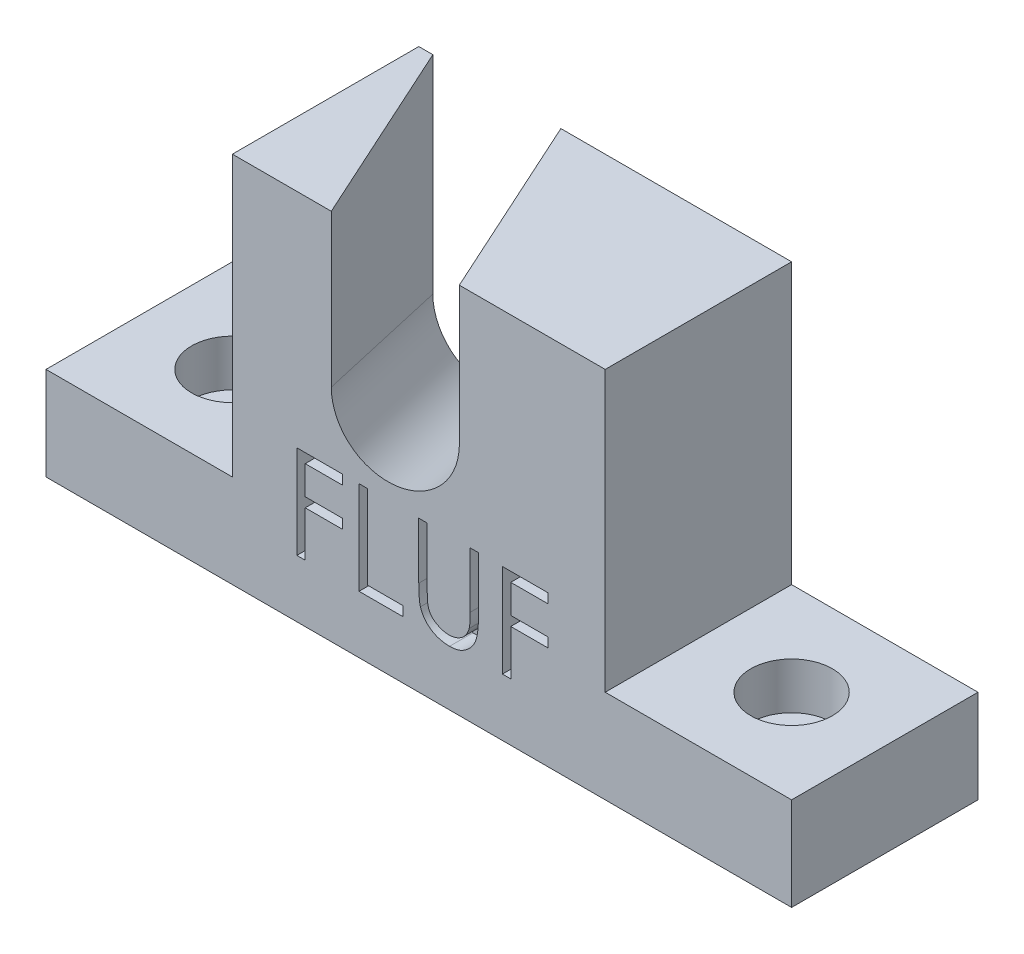
from build123d import *

# Parameters (mm, degrees)
BOSS_EXTRUDE1_DEPTH                              = 25.4
CBORE_FOR_1_4_SOCKET_HEAD_CAP_SCREW1_D           = 6.7564
CBORE_FOR_1_4_SOCKET_HEAD_CAP_SCREW1_CBORE_D     = 11.1125
CBORE_FOR_1_4_SOCKET_HEAD_CAP_SCREW1_CBORE_DEPTH = 6.35
SKETCH6_R                                        = 7.9375
CUT_EXTRUDE2_DEPTH                               = 88.530033839
CUT_EXTRUDE3_DEPTH                               = 3.175


with BuildPart() as part:
    # Sketch1 → Boss-Extrude1 (new body)
    with BuildSketch(Plane.XY):
        Polygon((25.4, 12.7), (50.8, 12.7), (50.8, 0), (-50.8, 0), (-50.8, 12.7), (-25.4, 12.7), (-25.4, 50.8), (25.4, 50.8), align=None)
    extrude(amount=BOSS_EXTRUDE1_DEPTH)

    # CBORE for 1/4 Socket Head Cap Screw1 (through all)
    with Locations(Plane(origin=(0, 12.7, 0), x_dir=(1, 0, 0), z_dir=(0, 1, 0))):
        with Locations((-38.1, -12.7), (38.1, -12.7)):
            CounterBoreHole(CBORE_FOR_1_4_SOCKET_HEAD_CAP_SCREW1_D / 2, CBORE_FOR_1_4_SOCKET_HEAD_CAP_SCREW1_CBORE_D / 2, CBORE_FOR_1_4_SOCKET_HEAD_CAP_SCREW1_CBORE_DEPTH)

    # Sketch6 → Cut-Extrude2 (cut, through all)
    with BuildSketch(Plane(origin=(8.61013147, 38.672281651, 51.345863849), x_dir=(-0.9161407044196058, 0.08766347581543056, 0.39115383765662576), z_dir=(-0.40011338654688333, -0.2593820230581922, -0.878993881673942))):
        Circle(SKETCH6_R)
        with BuildLine():
            Line((-4.081369276, 42.668005296), (-7.904732998, 0.720487673))
            ThreePointArc((-7.904732998, 0.720487673), (0.360616196, 7.929304018), (7.9375, 0))
            ThreePointArc((7.9375, 0), (7.929304018, -0.360616196), (7.904732998, -0.720487673))
            Line((7.904732998, -0.720487673), (11.728096719, 41.227029949))
            Line((11.728096719, 41.227029949), (-4.081369276, 42.668005296))
        make_face()
    extrude(amount=CUT_EXTRUDE2_DEPTH, mode=Mode.SUBTRACT)

    # Sketch7 → Cut-Extrude3 (cut)
    with BuildSketch(Plane.XY.offset(25.4)):
        Polygon((-16.614726636, 20.539659198), (-10.427547149, 20.539659198), (-10.427547149, 19.237095095), (-15.474983047, 19.237095095), (-15.474983047, 15.329402787), (-10.427547149, 15.329402787), (-10.427547149, 14.026838685), (-15.474983047, 14.026838685), (-15.474983047, 7.839659198), (-16.614726636, 7.839659198), align=None)
        Polygon((-8.14805997, 20.539659198), (-7.00831638, 20.539659198), (-7.00831638, 9.1422233), (-2.123700995, 9.1422233), (-2.123700995, 7.839659198), (-8.14805997, 7.839659198), align=None)
        with BuildLine():
            Line((-0.007034329, 20.539659198), (1.132709261, 20.539659198))
            Line((1.132709261, 20.539659198), (1.132709261, 12.930344294))
            add(Edge.make_bspline(
                [(1.132709261, 12.930344294), (1.132539647, 12.822645624), (1.132217776, 12.618268839), (1.134367755, 12.327372434), (1.140388891, 12.068755225), (1.144184956, 11.841420336), (1.152629852, 11.646410938), (1.159517051, 11.482670525), (1.168372785, 11.350974419), (1.179015812, 11.274117916), (1.183590671, 11.241081473)],
                knots=[0, 0, 0, 0, 1.528628734, 2.90083645, 4.128790002, 5.200304208, 6.127813768, 6.898992206, 7.526736466, 8, 8, 8, 8], degree=3))
            add(Edge.make_bspline(
                [(1.183590671, 11.241081473), (1.20237745, 11.121894646), (1.238892441, 10.890236743), (1.331952154, 10.560369549), (1.461918515, 10.263075401), (1.615926127, 9.989077287), (1.818881603, 9.746001609), (2.062008717, 9.522076469), (2.356568048, 9.326235921), (2.684085103, 9.147162975), (3.037091536, 9.003235391), (3.397812417, 8.894402326), (3.760825513, 8.828076032), (4.003853312, 8.820396019), (4.124536184, 8.816582275)],
                knots=[0, 0, 0, 0, 1.035780045, 2.013197591, 2.933192213, 3.817615948, 4.702609284, 5.640816605, 6.646850145, 7.73207398, 8.84249596, 9.914020372, 10.964143139, 12, 12, 12, 12], degree=3))
            add(Edge.make_bspline(
                [(4.124536184, 8.816582275), (4.228145471, 8.820478817), (4.434765624, 8.828249397), (4.741766101, 8.876369446), (5.040760781, 8.963094356), (5.333226105, 9.074998622), (5.607368249, 9.222854167), (5.863340167, 9.39365407), (6.0918093, 9.593990678), (6.300299749, 9.815697642), (6.481855087, 10.065850631), (6.639230373, 10.339002731), (6.768138746, 10.639264647), (6.831796679, 10.850282122), (6.864500126, 10.958689646)],
                knots=[0, 0, 0, 0, 0.994687771, 1.983630487, 2.973142513, 3.978332533, 4.983357753, 5.956394766, 6.925816176, 7.893390482, 8.871859704, 9.88551698, 10.913711441, 12, 12, 12, 12], degree=3))
            add(Edge.make_bspline(
                [(6.864500126, 10.958689646), (6.875386295, 11.00349733), (6.899645067, 11.103346908), (6.922312916, 11.272152734), (6.945922308, 11.471322711), (6.962303748, 11.702287861), (6.97827389, 11.964274247), (6.987828183, 12.258646667), (6.992244274, 12.584336211), (6.993560286, 12.811619626), (6.994247723, 12.930344294)],
                knots=[0, 0, 0, 0, 0.558680831, 1.244966039, 2.062412453, 2.990489873, 4.051219941, 5.244515665, 6.560634259, 8, 8, 8, 8], degree=3))
            Line((6.994247723, 12.930344294), (6.994247723, 20.539659198))
            Line((6.994247723, 20.539659198), (8.133991312, 20.539659198))
            Line((8.133991312, 20.539659198), (8.133991312, 12.869286602))
            add(Edge.make_bspline(
                [(8.133991312, 12.869286602), (8.133069218, 12.731043912), (8.131269696, 12.461254899), (8.115664747, 12.06591711), (8.090783633, 11.690893435), (8.055629714, 11.336133462), (8.009049731, 11.002906656), (7.957251074, 10.688292211), (7.89128534, 10.394548495), (7.814238427, 10.119385151), (7.726160124, 9.85745486), (7.612073671, 9.608866458), (7.483533343, 9.366062779), (7.331080174, 9.132716213), (7.1597703, 8.907793577), (6.965817058, 8.692658933), (6.755635103, 8.483874394), (6.525730415, 8.286795554), (6.279892795, 8.106061212), (6.01885352, 7.947137871), (5.744617813, 7.812795031), (5.457898526, 7.702210962), (5.158573304, 7.619063702), (4.846634599, 7.55710528), (4.521372383, 7.5218998), (4.300157774, 7.516667654), (4.188137947, 7.514018172)],
                knots=[0, 0, 0, 0, 1.316592851, 2.569410997, 3.76748051, 4.895814652, 5.963796859, 6.97159953, 7.931736103, 8.829262218, 9.692595152, 10.560224239, 11.431080259, 12.30701507, 13.211635791, 14.121146779, 15.063487852, 16.031507147, 17.00238618, 17.966455255, 18.938106653, 19.907068911, 20.888905087, 21.893141452, 22.933117798, 24, 24, 24, 24], degree=3))
            add(Edge.make_bspline(
                [(4.188137947, 7.514018172), (4.065967203, 7.516865749), (3.826268641, 7.522452684), (3.473070511, 7.554466663), (3.134473285, 7.614767694), (2.806900816, 7.691548061), (2.494812841, 7.797443337), (2.194028057, 7.921170818), (1.909697986, 8.073125449), (1.637209948, 8.242192903), (1.383845832, 8.432419447), (1.151263827, 8.63975665), (0.939079954, 8.860883162), (0.750870684, 9.098193061), (0.58351776, 9.349840684), (0.439353843, 9.616537925), (0.3155715, 9.898181529), (0.251684814, 10.093954571), (0.219387947, 10.192924422)],
                knots=[0, 0, 0, 0, 1.13879206, 2.234305948, 3.301075583, 4.341971843, 5.366689343, 6.369221514, 7.369726634, 8.367512178, 9.355451585, 10.318319045, 11.268648973, 12.207971039, 13.137398894, 14.081662264, 15.030215811, 16, 16, 16, 16], degree=3))
            add(Edge.make_bspline(
                [(0.219387947, 10.192924422), (0.200602259, 10.260534049), (0.159855683, 10.407180837), (0.116221031, 10.649883238), (0.079539506, 10.929337368), (0.045047909, 11.245562354), (0.024695405, 11.598803299), (0.006852127, 11.988907079), (-0.007160032, 12.416345397), (-0.007077401, 12.714086068), (-0.007034329, 12.869286602)],
                knots=[0, 0, 0, 0, 0.625038921, 1.35572334, 2.194682327, 3.136881307, 4.189498639, 5.346923369, 6.617055217, 8, 8, 8, 8], degree=3))
            Line((-0.007034329, 12.869286602), (-0.007034329, 20.539659198))
        make_face()
        Polygon((11.390401569, 20.539659198), (17.577581056, 20.539659198), (17.577581056, 19.237095095), (12.530145158, 19.237095095), (12.530145158, 15.329402787), (17.577581056, 15.329402787), (17.577581056, 14.026838685), (12.530145158, 14.026838685), (12.530145158, 7.839659198), (11.390401569, 7.839659198), align=None)
    extrude(amount=-CUT_EXTRUDE3_DEPTH, mode=Mode.SUBTRACT)


solid = part.part
